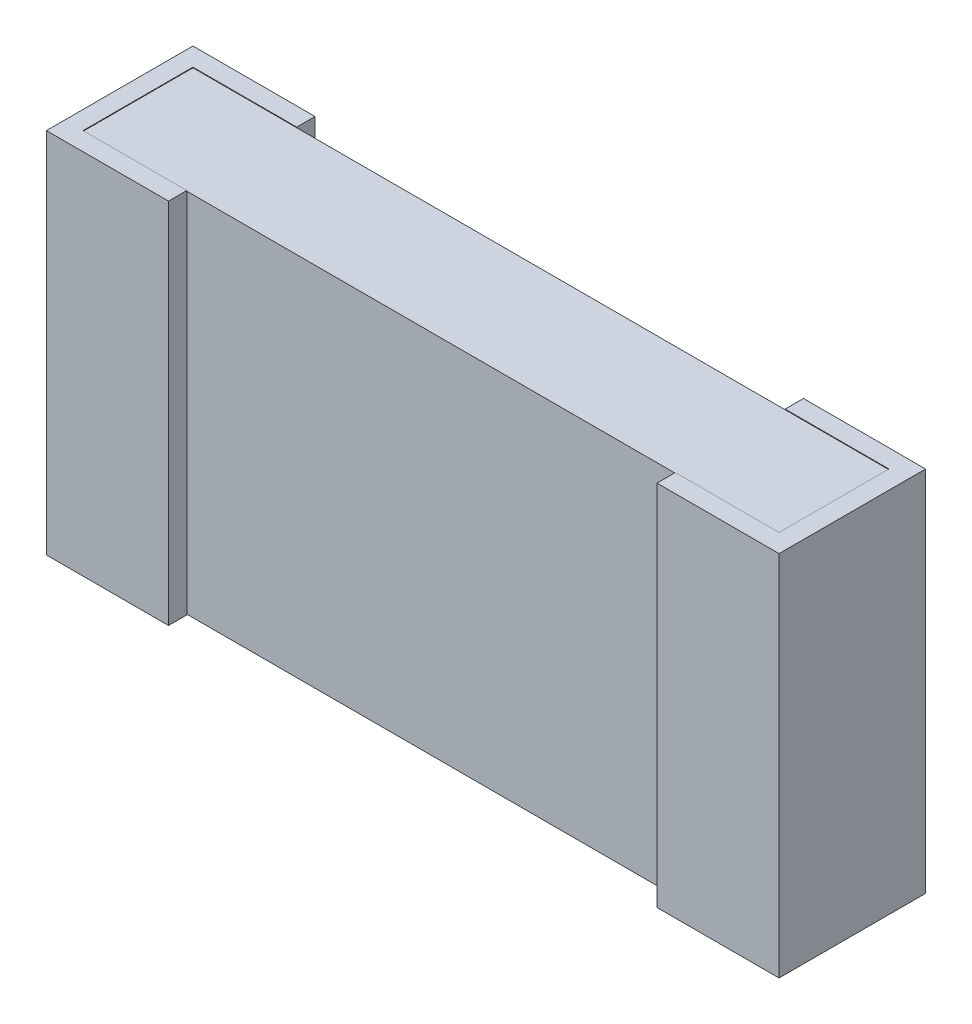
from build123d import *

# Parameters (mm, degrees)
SKETCH2_W           = 2.8956
SKETCH2_H           = 0.4572
BASE_EXTRUDE_DEPTH  = 0.762
BOSS_EXTRUDE8_DEPTH = 1.52908


with BuildPart() as part:
    # Sketch2 → Base-Extrude (new body, symmetric)
    with BuildSketch(Plane(origin=(0, 0, 0), x_dir=(1, 0, 0), z_dir=(0, 1, 0))):
        with Locations((1.524, -0.3048)):
            Rectangle(SKETCH2_W, SKETCH2_H)
    extrude(amount=BASE_EXTRUDE_DEPTH, both=True)

    # Sketch3 → Boss-Extrude8 (add)
    with BuildSketch(Plane(origin=(0, 0.76454, 0), x_dir=(-1, 0, 0), z_dir=(0, 1, 0))):
        Polygon((-0.508, 0.6096), (-0.508, 0.5334), (-0.0762, 0.5334), (-0.0762, 0.0762), (-0.508, 0.0762), (-0.508, 0), (0, 0), (0, 0.6096), align=None)
    boss_extrude8 = extrude(amount=-BOSS_EXTRUDE8_DEPTH)

    # Mirror5: Boss-Extrude8 across plane
    add(boss_extrude8.mirror(Plane(origin=(1.524, 0, 0), x_dir=(0, 0, 1), z_dir=(1, 0, 0))))


solid = part.part
